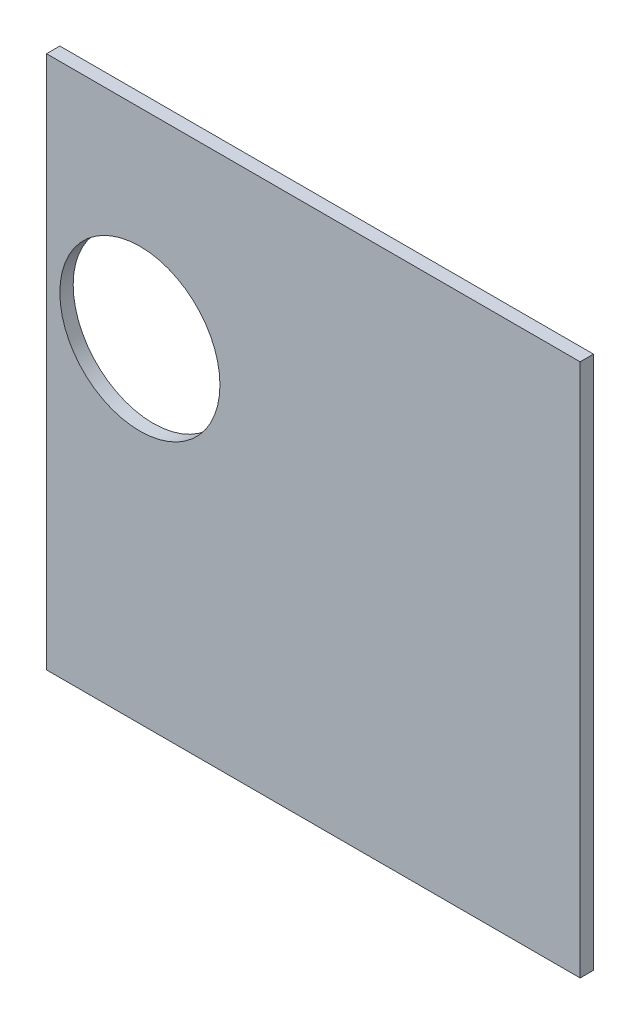
from build123d import *

# Parameters (mm, degrees)
SKETCH1_W           = 254
SKETCH1_H           = 254
BOSS_EXTRUDE1_DEPTH = 6.35
SKETCH2_R           = 38.1
CUT_EXTRUDE1_DEPTH  = 7.35


with BuildPart() as part:
    # Sketch1 → Boss-Extrude1 (new body)
    with BuildSketch(Plane.XY):
        with Locations((127, 127)):
            Rectangle(SKETCH1_W, SKETCH1_H)
    extrude(amount=BOSS_EXTRUDE1_DEPTH)

    # Sketch2 → Cut-Extrude1 (cut, through all)
    with BuildSketch(Plane.XY.offset(6.35)):
        with Locations((44.45, 158.75)):
            Circle(SKETCH2_R)
    extrude(amount=-CUT_EXTRUDE1_DEPTH, mode=Mode.SUBTRACT)


solid = part.part
